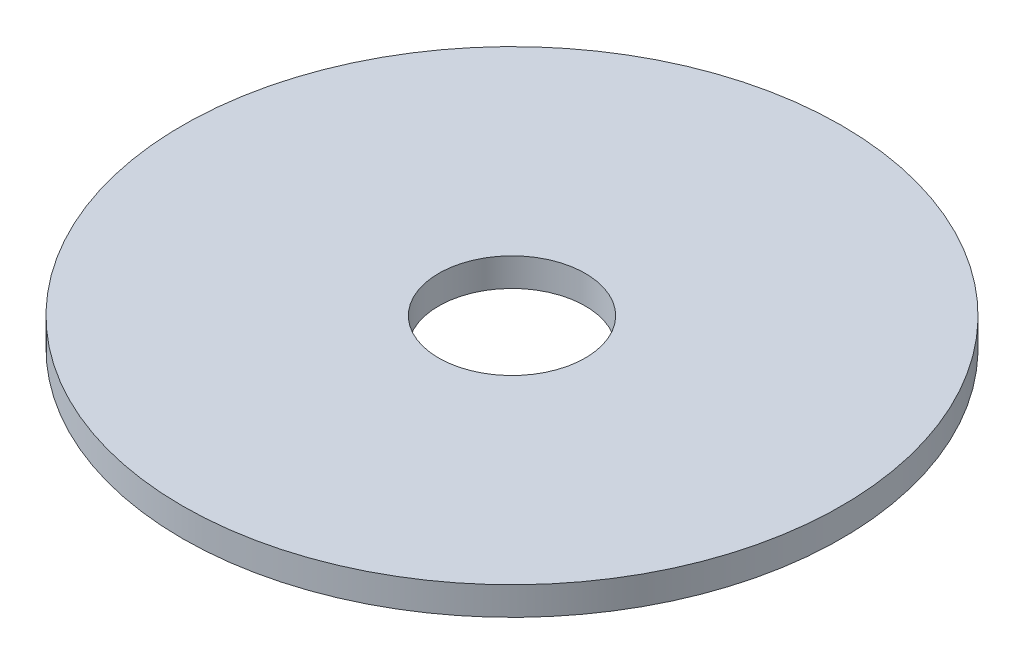
from build123d import *

# Parameters (mm, degrees)
SKETCH1_R           = 186.5
SKETCH1_R_2         = 41.5
BOSS_EXTRUDE1_DEPTH = 16
SCALE1_SCALE        = 0.1


with BuildPart() as part:
    # Sketch1 → Boss-Extrude1 (new body)
    with BuildSketch(Plane(origin=(0, 0, 0), x_dir=(1, 0, 0), z_dir=(0, 1, 0))):
        Circle(SKETCH1_R)
        Circle(SKETCH1_R_2, mode=Mode.SUBTRACT)
    extrude(amount=BOSS_EXTRUDE1_DEPTH)


with BuildPart() as part_1:
    # Scale1: scaled about (0, 8, 0)
    add(part.part.scale(SCALE1_SCALE).moved(Location((0, 7.2, 0))))


solid = part_1.part
